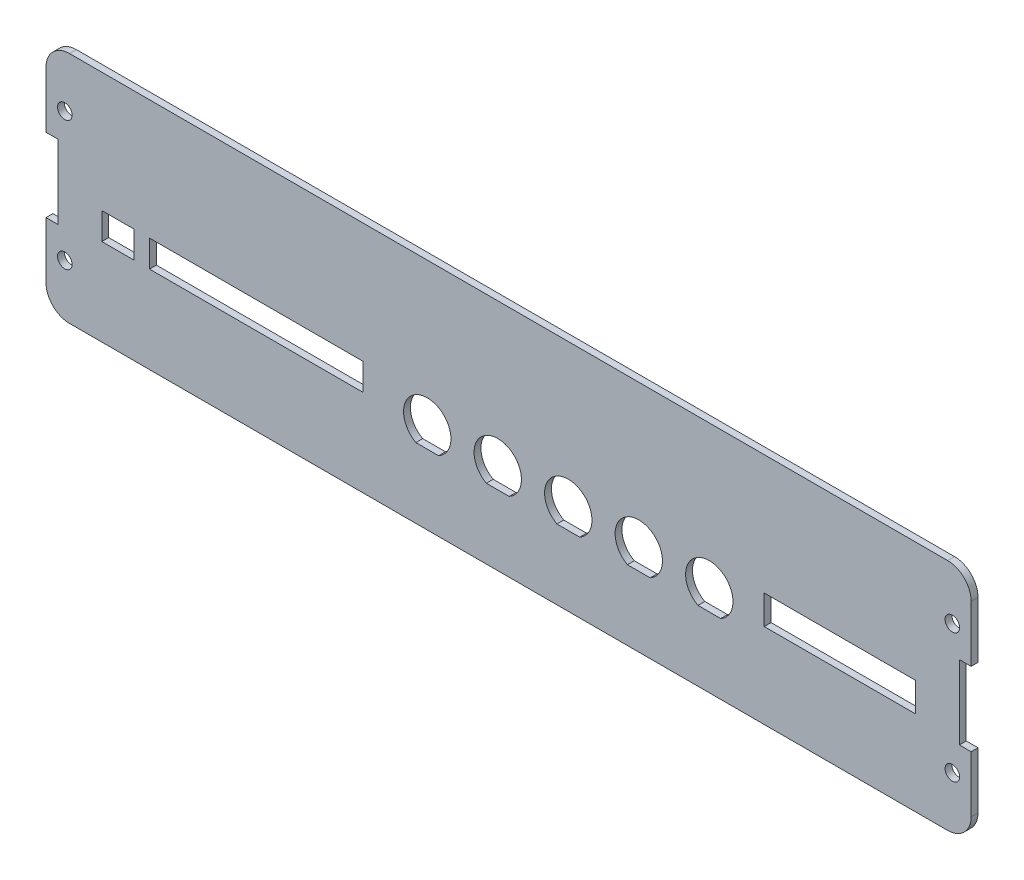
from build123d import *

# Parameters (mm, degrees)
MAINBODY_DEPTH    = 1.8542
SKETCH3_R         = 1.9685
MOUNTHOLES_DEPTH  = 129.907885308
PANELCUTOUT_REACH = 130.908
SKETCH4_W         = 40.934
SKETCH4_H         = 7.854
SKETCH4_W_2       = 57.654
SKETCH4_H_2       = 7.254
SKETCH4_W_3       = 8.654


with BuildPart() as part:
    # Sketch2 → MainBody (new body)
    with BuildSketch(Plane.XY):
        with BuildLine():
            Line((118.618, 31.5722), (-118.618, 31.5722))
            ThreePointArc((-118.618, 31.5722), (-123.108128061, 29.712328061), (-124.968, 25.2222))
            Line((-124.968, 25.2222), (-124.968, 9.9822))
            Line((-124.968, 9.9822), (-121.793, 9.9822))
            Line((-121.793, 9.9822), (-121.793, -9.9822))
            Line((-121.793, -9.9822), (-124.968, -9.9822))
            Line((-124.968, -9.9822), (-124.968, -25.2222))
            ThreePointArc((-124.968, -25.2222), (-123.108128061, -29.712328061), (-118.618, -31.5722))
            Line((-118.618, -31.5722), (118.618, -31.5722))
            ThreePointArc((118.618, -31.5722), (123.108128061, -29.712328061), (124.968, -25.2222))
            Line((124.968, -25.2222), (124.968, -9.9822))
            Line((124.968, -9.9822), (121.793, -9.9822))
            Line((121.793, -9.9822), (121.793, 9.9822))
            Line((121.793, 9.9822), (124.968, 9.9822))
            Line((124.968, 9.9822), (124.968, 25.2222))
            ThreePointArc((124.968, 25.2222), (123.108128061, 29.712328061), (118.618, 31.5722))
        make_face()
    extrude(amount=MAINBODY_DEPTH)

    # Sketch3 → MountHoles (cut, through all)
    with BuildSketch(Plane.XY.offset(1.8542)):
        with Locations((-119.888, 17.4625)):
            Circle(SKETCH3_R)
        with Locations((119.888, 17.4625)):
            Circle(SKETCH3_R)
        with Locations((119.888, -17.4625)):
            Circle(SKETCH3_R)
        with Locations((-119.888, -17.4625)):
            Circle(SKETCH3_R)
    extrude(amount=-MOUNTHOLES_DEPTH, mode=Mode.SUBTRACT)

    # Sketch4 → PanelCutout (cut, up to next)
    with BuildSketch(Plane.XY.offset(1.8542), mode=Mode.PRIVATE) as panelcutout_sk1:
        with BuildLine():
            Line((51.153291776, -12.65754977), (57.304708224, -12.65754977))
            ThreePointArc((57.304708224, -12.65754977), (54.229, -0.64334977), (51.153291776, -12.65754977))
        make_face()
    panelcutout_tool1 = extrude(panelcutout_sk1.sketch, amount=-PANELCUTOUT_REACH, mode=Mode.PRIVATE) & part.part
    # Sketch4 → PanelCutout (cut, up to next)
    with BuildSketch(Plane.XY.offset(1.8542), mode=Mode.PRIVATE) as panelcutout_sk2:
        with Locations((89.535, -4.72055)):
            Rectangle(SKETCH4_W, SKETCH4_H)
    panelcutout_tool2 = extrude(panelcutout_sk2.sketch, amount=-PANELCUTOUT_REACH, mode=Mode.PRIVATE) & part.part
    # Sketch4 → PanelCutout (cut, up to next)
    with BuildSketch(Plane.XY.offset(1.8542), mode=Mode.PRIVATE) as panelcutout_sk3:
        with BuildLine():
            Line((32.103291776, -12.65754977), (38.254708224, -12.65754977))
            ThreePointArc((38.254708224, -12.65754977), (35.179, -0.64334977), (32.103291776, -12.65754977))
        make_face()
    panelcutout_tool3 = extrude(panelcutout_sk3.sketch, amount=-PANELCUTOUT_REACH, mode=Mode.PRIVATE) & part.part
    # Sketch4 → PanelCutout (cut, up to next)
    with BuildSketch(Plane.XY.offset(1.8542), mode=Mode.PRIVATE) as panelcutout_sk4:
        with BuildLine():
            Line((13.053291776, -12.65754977), (19.204708224, -12.65754977))
            ThreePointArc((19.204708224, -12.65754977), (16.129, -0.64334977), (13.053291776, -12.65754977))
        make_face()
    panelcutout_tool4 = extrude(panelcutout_sk4.sketch, amount=-PANELCUTOUT_REACH, mode=Mode.PRIVATE) & part.part
    # Sketch4 → PanelCutout (cut, up to next)
    with BuildSketch(Plane.XY.offset(1.8542), mode=Mode.PRIVATE) as panelcutout_sk5:
        with BuildLine():
            Line((-5.996708224, -12.65754977), (0.154708224, -12.65754977))
            ThreePointArc((0.154708224, -12.65754977), (-2.921, -0.64334977), (-5.996708224, -12.65754977))
        make_face()
    panelcutout_tool5 = extrude(panelcutout_sk5.sketch, amount=-PANELCUTOUT_REACH, mode=Mode.PRIVATE) & part.part
    # Sketch4 → PanelCutout (cut, up to next)
    with BuildSketch(Plane.XY.offset(1.8542), mode=Mode.PRIVATE) as panelcutout_sk6:
        with BuildLine():
            Line((-25.046708224, -12.65754977), (-18.895291776, -12.65754977))
            ThreePointArc((-18.895291776, -12.65754977), (-21.971, -0.64334977), (-25.046708224, -12.65754977))
        make_face()
    panelcutout_tool6 = extrude(panelcutout_sk6.sketch, amount=-PANELCUTOUT_REACH, mode=Mode.PRIVATE) & part.part
    # Sketch4 → PanelCutout (cut, up to next)
    with BuildSketch(Plane.XY.offset(1.8542), mode=Mode.PRIVATE) as panelcutout_sk7:
        with Locations((-68.171, -4.42055)):
            Rectangle(SKETCH4_W_2, SKETCH4_H_2)
    panelcutout_tool7 = extrude(panelcutout_sk7.sketch, amount=-PANELCUTOUT_REACH, mode=Mode.PRIVATE) & part.part
    # Sketch4 → PanelCutout (cut, up to next)
    with BuildSketch(Plane.XY.offset(1.8542), mode=Mode.PRIVATE) as panelcutout_sk8:
        with Locations((-105.5650001, -4.42055)):
            Rectangle(SKETCH4_W_3, SKETCH4_H_2)
    panelcutout_tool8 = extrude(panelcutout_sk8.sketch, amount=-PANELCUTOUT_REACH, mode=Mode.PRIVATE) & part.part
    add(panelcutout_tool1.solids().sort_by_distance((54.229, -6.889516, 1.8542))[0], mode=Mode.SUBTRACT)
    add(panelcutout_tool2.solids().sort_by_distance((89.535, -4.72055, 1.8542))[0], mode=Mode.SUBTRACT)
    add(panelcutout_tool3.solids().sort_by_distance((35.179, -6.889516, 1.8542))[0], mode=Mode.SUBTRACT)
    add(panelcutout_tool4.solids().sort_by_distance((16.129, -6.889516, 1.8542))[0], mode=Mode.SUBTRACT)
    add(panelcutout_tool5.solids().sort_by_distance((-2.921, -6.889516, 1.8542))[0], mode=Mode.SUBTRACT)
    add(panelcutout_tool6.solids().sort_by_distance((-21.971, -6.889516, 1.8542))[0], mode=Mode.SUBTRACT)
    add(panelcutout_tool7.solids().sort_by_distance((-68.171, -4.42055, 1.8542))[0], mode=Mode.SUBTRACT)
    add(panelcutout_tool8.solids().sort_by_distance((-105.565, -4.42055, 1.8542))[0], mode=Mode.SUBTRACT)


solid = part.part
